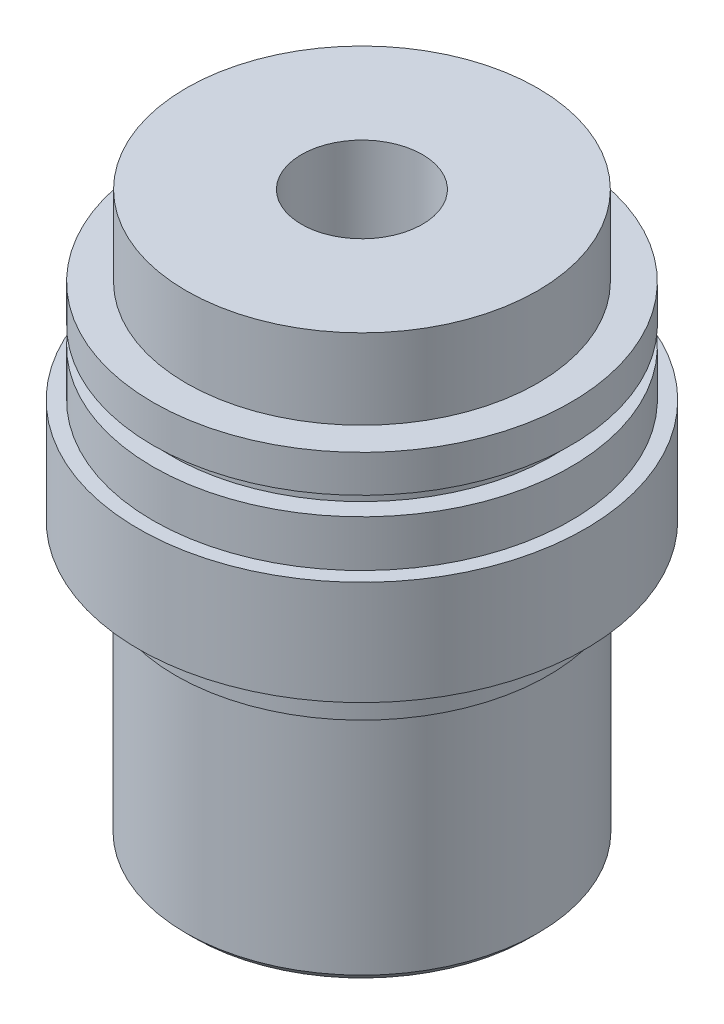
from build123d import *

# Parameters (mm, degrees)
CHAMFER1_SIZE = 0.45


with BuildPart() as part:
    # Sketch1 → Revolve1 (revolve)
    with BuildSketch(Plane.XY):
        Polygon((3.25, 0), (3.25, 30.33), (9.44, 30.33), (9.44, 26.03), (11.225, 26.03), (11.225, 24.03), (10.225, 24.03), (10.225, 23.03), (11.225, 23.03), (11.225, 20.53), (12, 20.53), (12, 14.93), (10, 14.93), (10, 12.7), (9.46, 12.7), (9.46, 0), align=None)
    revolve(axis=Axis((0, 0, 0), (0, 1, 0)))

    # Chamfer1
    chamfer1_edges = [part.edges().sort_by_distance(p)[0] for p in [
        (-9.46, 0, 0),
        (-10, 14.93, 0),
        (-3.25, 0, 0),
    ]]
    chamfer(chamfer1_edges, length=CHAMFER1_SIZE)


solid = part.part
